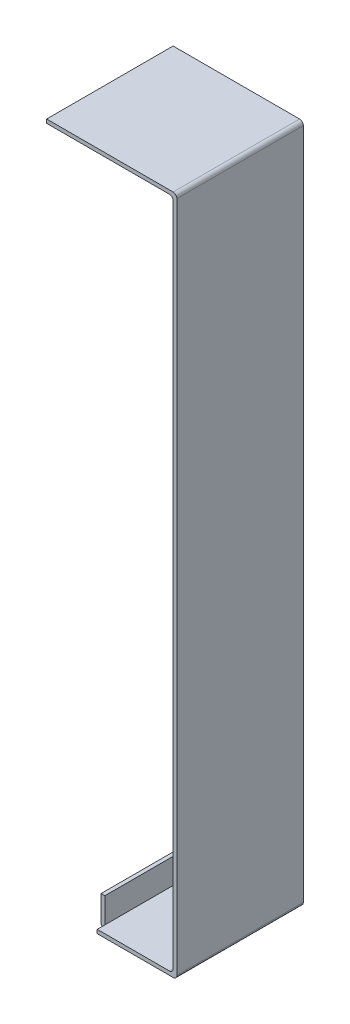
from build123d import *

# Parameters (mm, degrees)
EXTRUDE_2_DEPTH     = 50
SKETCH_2_W          = 3
SKETCH_2_H          = 11.5
CUT_EXTRUDE_1_DEPTH = 1.5
FILLET_1_R          = 1.5


with BuildPart() as part:
    # 草图1 → 凸台-拉伸2 (new body)
    with BuildSketch(Plane.XY):
        with BuildLine():
            Line((44.354602366, 43.972629848), (15.854602366, 43.972629848))
            Line((15.854602366, 43.972629848), (-4.145397634, 43.972629848))
            Line((-4.145397634, 43.972629848), (-4.145397634, 45.472629848))
            Line((-4.145397634, 45.472629848), (45.854602366, 45.472629848))
            ThreePointArc((45.854602366, 45.472629848), (46.915262538, 45.03329002), (47.354602366, 43.972629848))
            Line((47.354602366, 43.972629848), (47.354602366, -222.027370152))
            ThreePointArc((47.354602366, -222.027370152), (46.915262538, -223.088030324), (45.854602366, -223.527370152))
            Line((45.854602366, -223.527370152), (14.354602366, -223.527370152))
            Line((14.354602366, -223.527370152), (14.354602366, -212.027370152))
            Line((14.354602366, -212.027370152), (15.854602366, -212.027370152))
            Line((15.854602366, -212.027370152), (15.854602366, -222.027370152))
            Line((15.854602366, -222.027370152), (44.354602366, -222.027370152))
            ThreePointArc((44.354602366, -222.027370152), (45.415262538, -221.588030324), (45.854602366, -220.527370152))
            Line((45.854602366, -220.527370152), (45.854602366, -212.027370152))
            Line((45.854602366, -212.027370152), (45.854602366, -36.027370152))
            Line((45.854602366, -36.027370152), (45.854602366, 42.472629848))
            ThreePointArc((45.854602366, 42.472629848), (45.415262538, 43.53329002), (44.354602366, 43.972629848))
        make_face()
    extrude(amount=EXTRUDE_2_DEPTH)

    # 草图2 → 切除-拉伸1 (cut)
    with BuildSketch(Plane.ZY.offset(-14.354602366)):
        with Locations((48.5, -217.777370152)):
            Rectangle(SKETCH_2_W, SKETCH_2_H)
        with Locations((1.5, -217.777370152)):
            Rectangle(SKETCH_2_W, SKETCH_2_H)
    extrude(amount=-CUT_EXTRUDE_1_DEPTH, mode=Mode.SUBTRACT)

    # 圆角1
    fillet_1_edges = [part.edges().sort_by_distance(p)[0] for p in [
        (14.354602366, -223.527370152, 25),
    ]]
    fillet(fillet_1_edges, radius=FILLET_1_R)


solid = part.part
